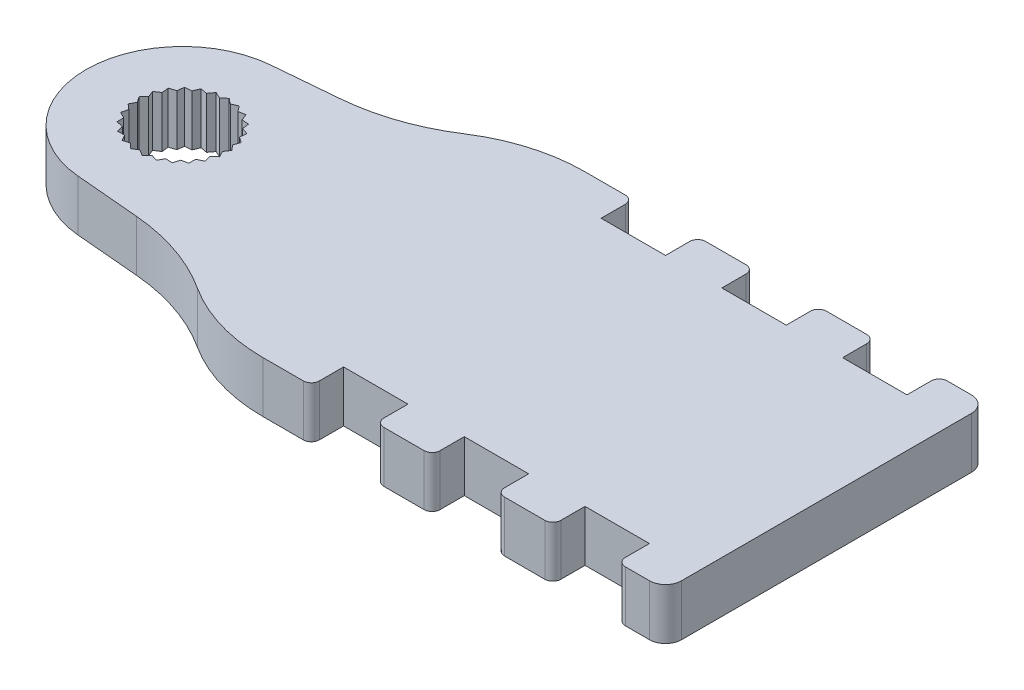
from build123d import *

# Parameters (mm, degrees)
BOSS_EXTRUDE1_DEPTH = 3.175
FILLET2_R           = 1
FILLET3_R           = 0.5


with BuildPart() as part:
    # Sketch1 → Boss-Extrude1 (new body)
    with BuildSketch(Plane(origin=(0, 0, 0), x_dir=(1, 0, 0), z_dir=(0, 1, 0))):
        with BuildLine():
            Line((40, -10), (40, 10))
            Line((40, 10), (37, 10))
            Line((37, 10), (37, 8))
            Line((37, 8), (33, 8))
            Line((33, 8), (33, 10))
            Line((33, 10), (29.5, 10))
            Line((29.5, 10), (29.5, 8))
            Line((29.5, 8), (25.5, 8))
            Line((25.5, 8), (25.5, 10))
            Line((25.5, 10), (22, 10))
            Line((22, 10), (22, 8))
            Line((22, 8), (18, 8))
            Line((18, 8), (18, 10))
            Line((18, 10), (15, 10))
            ThreePointArc((15, 10), (11.981600452, 9.564316032), (9.209618064, 8.29283265))
            ThreePointArc((9.209618064, 8.29283265), (6.463385686, 6.959896642), (3.477065544, 6.327122843))
            Line((3.477065544, 6.327122843), (-0.522934456, 5.977168189))
            ThreePointArc((-0.522934456, 5.977168189), (-6, 0), (-0.522934456, -5.977168189))
            Line((-0.522934456, -5.977168189), (3.477065544, -6.327122843))
            ThreePointArc((3.477065544, -6.327122843), (6.463385686, -6.959896642), (9.209618064, -8.29283265))
            ThreePointArc((9.209618064, -8.29283265), (11.981600452, -9.564316032), (15, -10))
            Line((15, -10), (18, -10))
            Line((18, -10), (18, -8))
            Line((18, -8), (22, -8))
            Line((22, -8), (22, -10))
            Line((22, -10), (25.5, -10))
            Line((25.5, -10), (25.5, -8))
            Line((25.5, -8), (29.5, -8))
            Line((29.5, -8), (29.5, -10))
            Line((29.5, -10), (33, -10))
            Line((33, -10), (33, -8))
            Line((33, -8), (37, -8))
            Line((37, -8), (37, -10))
            Line((37, -10), (40, -10))
        make_face()
        Polygon((0, 2.895), (-0.332133069, 2.629103958), (-0.719957223, 2.804048251), (-0.975530065, 2.463907688), (-1.394676887, 2.536907839), (-1.557630919, 2.143895035), (-1.981763872, 2.110364176), (-2.041860093, 1.689173573), (-2.444329344, 1.551218571), (-2.397791689, 1.128315123), (-2.753308615, 0.894604199), (-2.603061214, 0.496560484), (-2.889287379, 0.181778554), (-2.64477083, -0.166394877), (-2.843721591, -0.542468906), (-2.520299768, -0.818895035), (-2.619474317, -1.232631049), (-2.237469003, -1.419941007), (-2.230635838, -1.84534245), (-1.814049831, -1.931766863), (-1.701638305, -2.342104199), (-1.276647236, -2.322212702), (-1.06572058, -2.691702927), (-0.659028201, -2.566745377), (-0.362839711, -2.87217206), (0, -2.65), (0.362839711, -2.87217206), (0.659028201, -2.566745377), (1.06572058, -2.691702927), (1.276647236, -2.322212702), (1.701638305, -2.342104199), (1.814049831, -1.931766863), (2.230635838, -1.84534245), (2.237469003, -1.419941007), (2.619474317, -1.232631049), (2.520299768, -0.818895035), (2.843721591, -0.542468906), (2.64477083, -0.166394877), (2.889287379, 0.181778554), (2.603061214, 0.496560484), (2.753308615, 0.894604199), (2.397791689, 1.128315123), (2.444329344, 1.551218571), (2.041860093, 1.689173573), (1.981763872, 2.110364176), (1.557630919, 2.143895035), (1.394676887, 2.536907839), (0.975530065, 2.463907688), (0.719957223, 2.804048251), (0.332133069, 2.629103958), align=None, mode=Mode.SUBTRACT)
    extrude(amount=BOSS_EXTRUDE1_DEPTH)

    # Fillet2
    fillet2_edges = [part.edges().sort_by_distance(p)[0] for p in [
        (40, 1.5875, -10),
        (40, 1.5875, 10),
    ]]
    fillet(fillet2_edges, radius=FILLET2_R)

    # Fillet3
    fillet3_edges = [part.edges().sort_by_distance(p)[0] for p in [
        (37, 1.5875, -10),
        (37, 1.5875, 10),
        (33, 1.5875, 10),
        (29.5, 1.5875, 10),
        (25.5, 1.5875, 10),
        (22, 1.5875, 10),
        (18, 1.5875, 10),
        (18, 1.5875, -10),
        (22, 1.5875, -10),
        (25.5, 1.5875, -10),
        (29.5, 1.5875, -10),
        (33, 1.5875, -10),
    ]]
    fillet(fillet3_edges, radius=FILLET3_R)


solid = part.part
